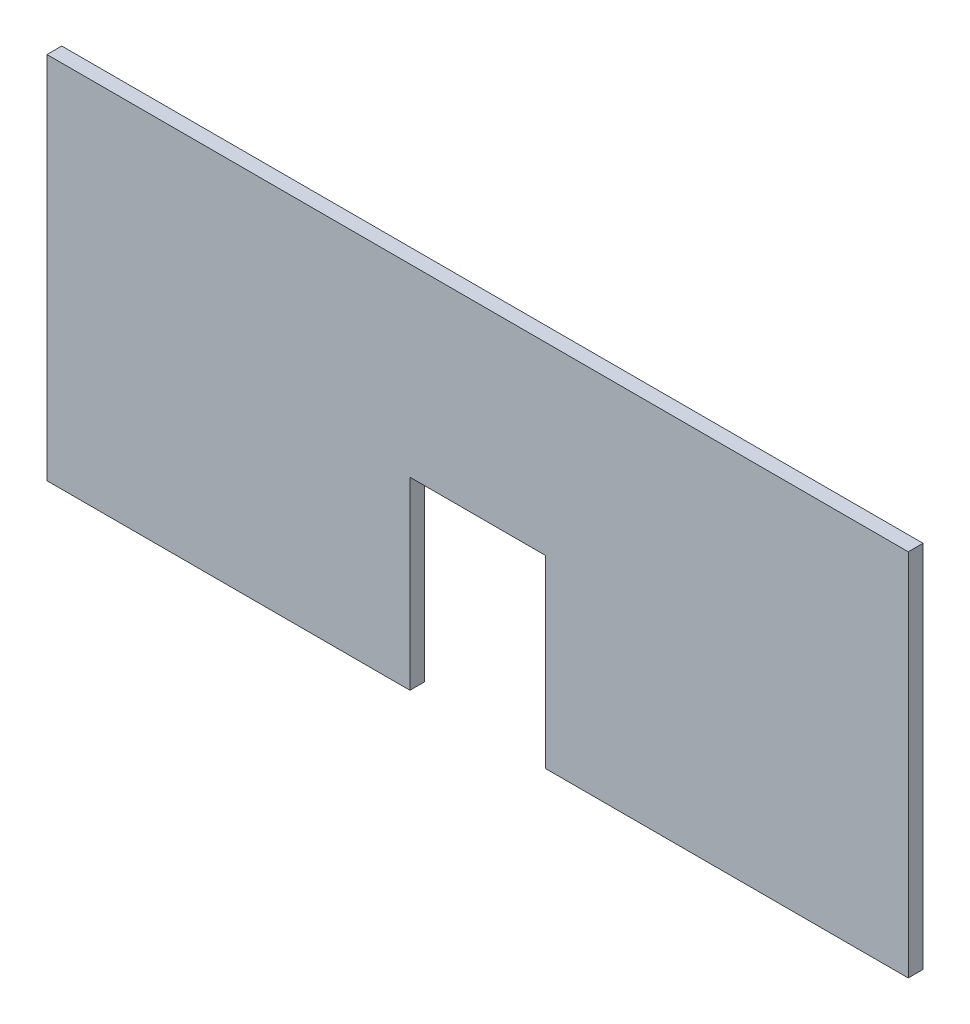
from build123d import *

# Parameters (mm, degrees)
BOSS_EXTRUDE1_DEPTH = 12


with BuildPart() as part:
    # Sketch1 → Boss-Extrude1 (new body)
    with BuildSketch(Plane.XY):
        Polygon((405, 0), (700, 0), (700, 300), (0, 300), (0, 0), (295, 0), (295, 150), (405, 150), align=None)
    extrude(amount=BOSS_EXTRUDE1_DEPTH)


solid = part.part
